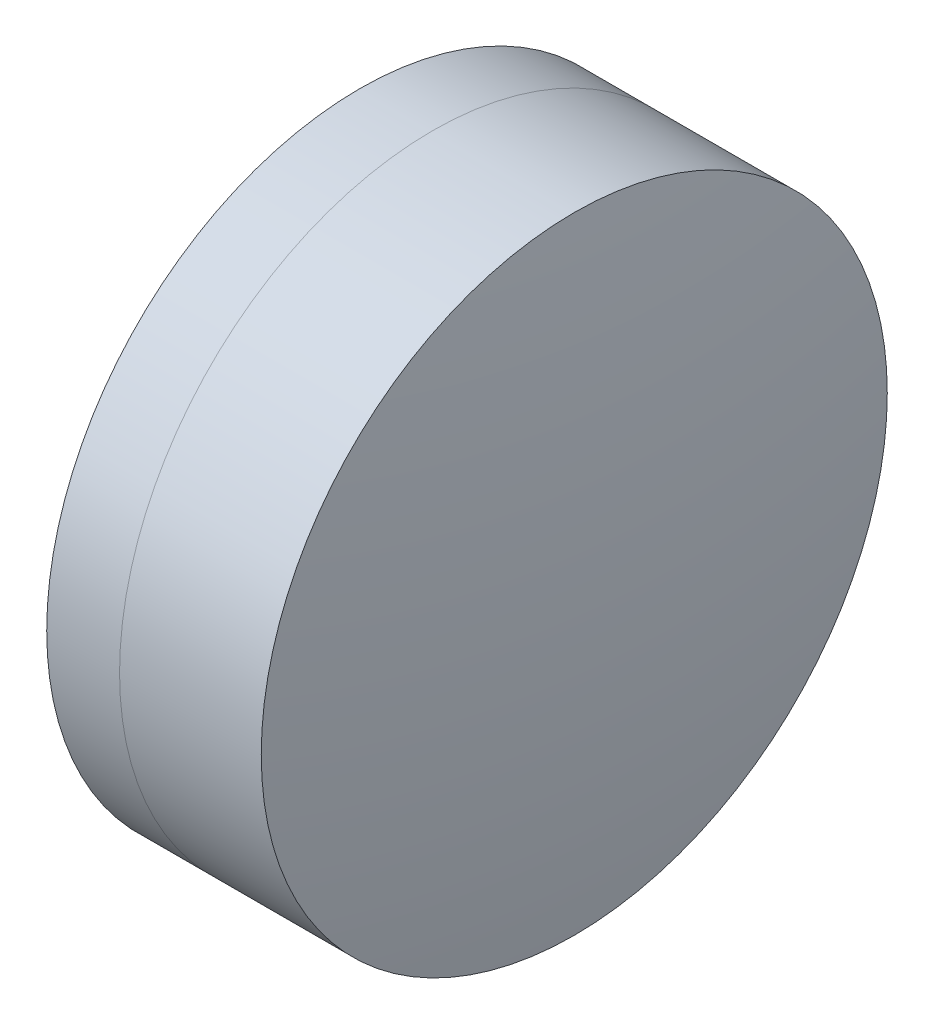
from build123d import *


with BuildPart() as part:
    # 草图1 one side → 旋转1 (revolve)
    with BuildSketch(Plane(origin=(0, 0, 0), x_dir=(1, 0, 0), z_dir=(0, 1, 0)), mode=Mode.PRIVATE) as revolve_1_sk:
        with BuildLine():
            ThreePointArc((-0.182094095, 6.25), (-0.914849844, 3.163104167), (-1.161079219, 0))
            Line((-1.161079219, 0), (2.688920781, 0))
            ThreePointArc((2.688920781, 0), (2.330343604, 3.204261524), (1.272351808, 6.25))
            Line((1.272351808, 6.25), (-0.182094095, 6.25))
        make_face()
    revolve(revolve_1_sk.sketch.rotate(Axis((-9.702612178, 0, 0), (1, 0, 0)), 180), axis=Axis((-9.702612178, 0, 0), (1, 0, 0)))  # turned: the seam where the file's is


with BuildPart() as body_2:
    # 草图2 one side → 旋转3 (revolve)
    with BuildSketch(Plane(origin=(0, 0, 0), x_dir=(1, 0, 0), z_dir=(0, 1, 0)), mode=Mode.PRIVATE) as revolve_3_sk:
        with BuildLine():
            Line((4.10139857, 6.25), (1.272351808, 6.25))
            ThreePointArc((1.272351808, 6.25), (2.330343604, 3.204261524), (2.688920781, 0))
            Line((2.688920781, 0), (4.578920781, 0))
            ThreePointArc((4.578920781, 0), (4.459366514, 3.134107826), (4.10139857, 6.25))
        make_face()
    revolve(revolve_3_sk.sketch.rotate(Axis((-0.551919993, 0, 0), (1, 0, 0)), 180), axis=Axis((-0.551919993, 0, 0), (1, 0, 0)))  # turned: the seam where the file's is


solid = Compound([part.part, body_2.part])
